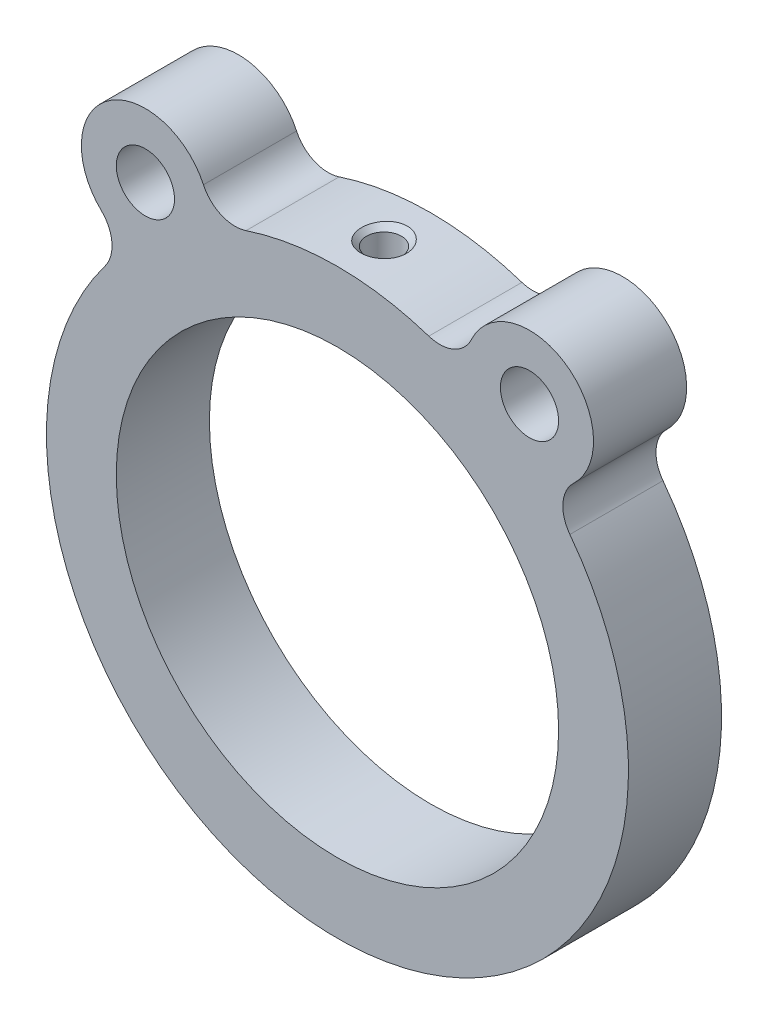
from build123d import *

# Parameters (mm, degrees)
BOSS_EXTRUDE1_DEPTH                                  = 4
BOSS_EXTRUDE1_DEPTH_BACK                             = 4
SKETCH1_R                                            = 19
SKETCH1_R_2                                          = 2.5
CSK_FOR_ST2_2_CROSS_RECESSED_CTSK_HEAD_T_D           = 3
CSK_FOR_ST2_2_CROSS_RECESSED_CTSK_HEAD_T_DEPTH       = 10.1
CSK_FOR_ST2_2_CROSS_RECESSED_CTSK_HEAD_T_CSINK_D     = 4
CSK_FOR_ST2_2_CROSS_RECESSED_CTSK_HEAD_T_CSINK_ANGLE = 90
CSK_FOR_ST2_2_CROSS_RECESSED_CTSK_HEAD_T_TIP         = 0.901290929


with BuildPart() as part:
    # Sketch1 → Boss-Extrude1 (new, two sides: drawn at the far end of the back side and taken through both)
    with BuildSketch(Plane.XY.offset(-BOSS_EXTRUDE1_DEPTH_BACK)):
        with BuildLine():
            ThreePointArc((19.968337429, 15.042124196), (19.37459007, 17.09256497), (20.294700731, 19.018763212))
            ThreePointArc((20.294700731, 19.018763212), (19.705993339, 27.468960361), (11.512732462, 25.318870955))
            ThreePointArc((11.512732462, 25.318870955), (9.982940481, 23.830053075), (7.850361432, 23.735455028))
            ThreePointArc((7.850361432, 23.735455028), (4.5e-08, 25), (-7.850361347, 23.735455056))
            ThreePointArc((-7.850361347, 23.735455056), (-9.982940439, 23.830053057), (-11.512732462, 25.318870955))
            ThreePointArc((-11.512732462, 25.318870955), (-19.705993339, 27.468960361), (-20.294700731, 19.018763212))
            ThreePointArc((-20.294700731, 19.018763212), (-19.374590067, 17.092564941), (-19.968337465, 15.042124148))
            ThreePointArc((-19.968337465, 15.042124148), (3e-08, -25), (19.968337429, 15.042124196))
        make_face()
        Circle(SKETCH1_R, mode=Mode.SUBTRACT)
        with Locations((16.5, 23)):
            Circle(SKETCH1_R_2, mode=Mode.SUBTRACT)
        with Locations((-16.5, 23)):
            Circle(SKETCH1_R_2, mode=Mode.SUBTRACT)
    extrude(amount=BOSS_EXTRUDE1_DEPTH + BOSS_EXTRUDE1_DEPTH_BACK)

    # CSK for ST2.2 Cross recessed CTSK head t
    with Locations(Plane(origin=(0, 25, 0), x_dir=(1, 0, 0), z_dir=(0, 1, 0))):
        with Locations((0, 0)):
            CounterSinkHole(CSK_FOR_ST2_2_CROSS_RECESSED_CTSK_HEAD_T_D / 2, CSK_FOR_ST2_2_CROSS_RECESSED_CTSK_HEAD_T_CSINK_D / 2, depth=CSK_FOR_ST2_2_CROSS_RECESSED_CTSK_HEAD_T_DEPTH, counter_sink_angle=CSK_FOR_ST2_2_CROSS_RECESSED_CTSK_HEAD_T_CSINK_ANGLE)
            with Locations((0, 0, -(CSK_FOR_ST2_2_CROSS_RECESSED_CTSK_HEAD_T_DEPTH + CSK_FOR_ST2_2_CROSS_RECESSED_CTSK_HEAD_T_TIP / 2))):  # 118° drill point
                Cone(0, CSK_FOR_ST2_2_CROSS_RECESSED_CTSK_HEAD_T_D / 2, CSK_FOR_ST2_2_CROSS_RECESSED_CTSK_HEAD_T_TIP, mode=Mode.SUBTRACT)


solid = part.part
